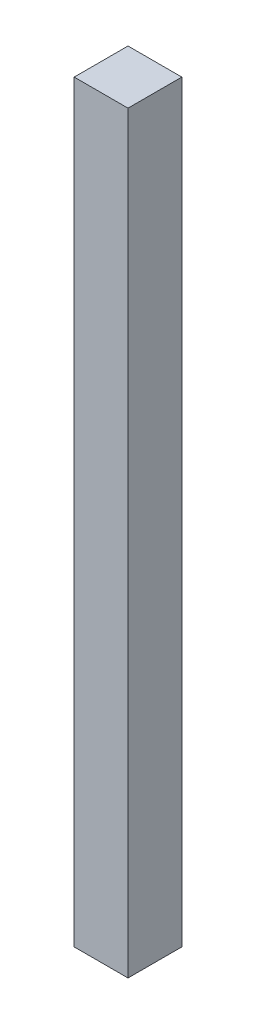
from build123d import *

# Parameters (mm, degrees)
SKETCH1_W           = 10
SKETCH1_H           = 10
BOSS_EXTRUDE1_DEPTH = 140


with BuildPart() as part:
    # Sketch1 → Boss-Extrude1 (new body)
    with BuildSketch(Plane(origin=(0, 0, 0), x_dir=(1, 0, 0), z_dir=(0, 1, 0))):
        with Locations((5, 5)):
            Rectangle(SKETCH1_W, SKETCH1_H)
    extrude(amount=BOSS_EXTRUDE1_DEPTH)


solid = part.part
